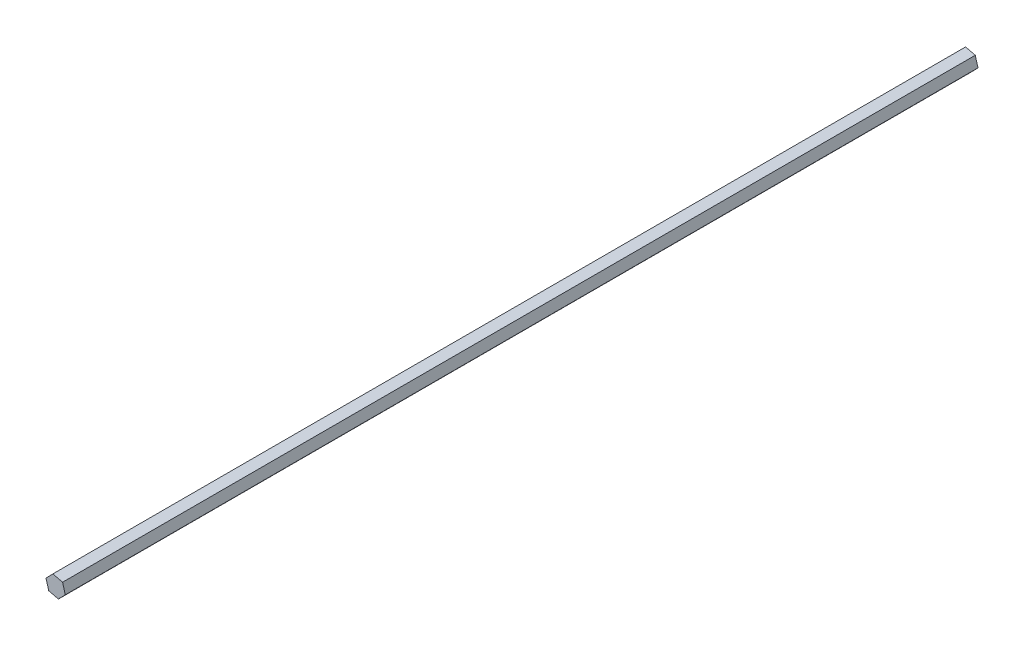
from build123d import *

# Parameters (mm, degrees)
BOSS_EXTRUDE1_DEPTH = 673.1


with BuildPart() as part:
    # Sketch1 → Boss-Extrude1 (new body)
    with BuildSketch(Plane.XY):
        Polygon((-7.113422827, 1.778355707), (-5.096812632, -5.271227023), (2.016610194, -7.049582729), (7.113422827, -1.778355707), (5.096812632, 5.271227023), (-2.016610194, 7.049582729), align=None)
    extrude(amount=BOSS_EXTRUDE1_DEPTH)


solid = part.part
